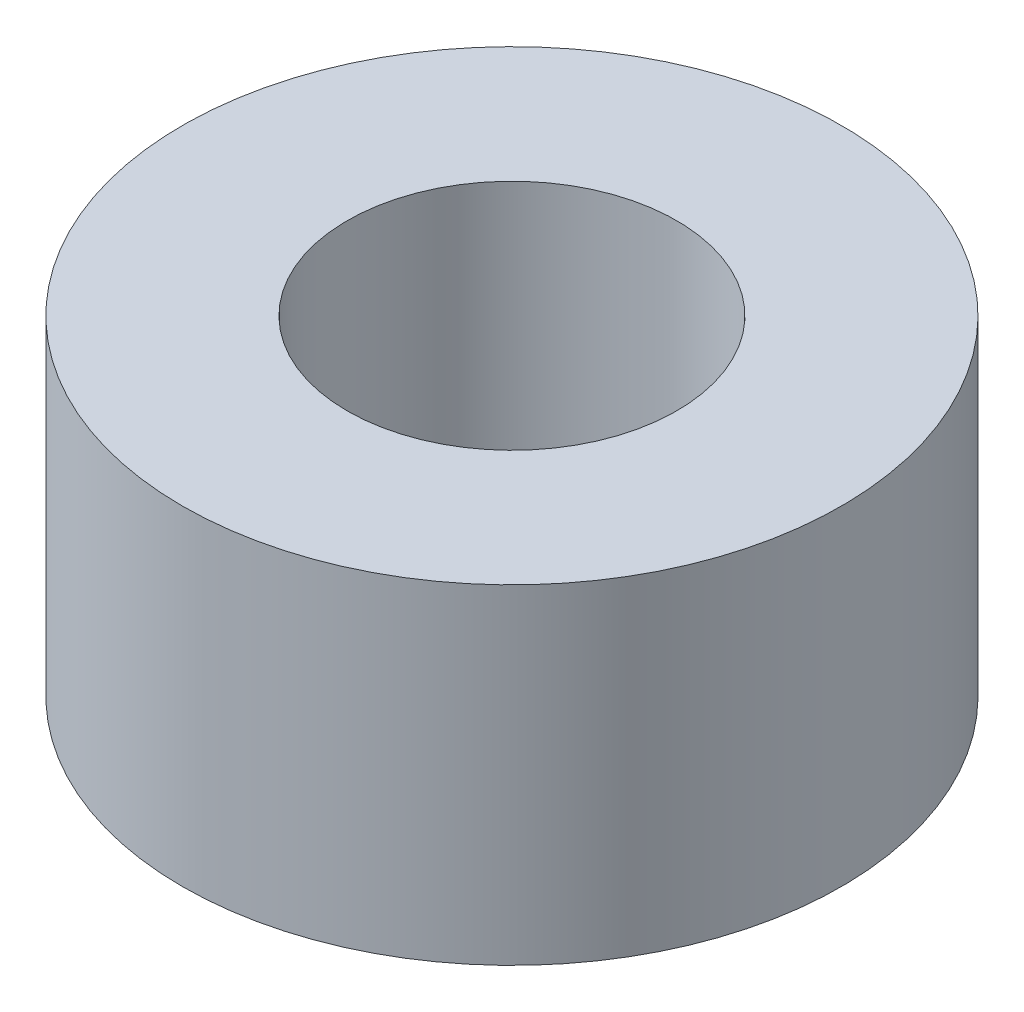
from build123d import *

# Parameters (mm, degrees)
SKETCH1_R           = 5.08
SKETCH1_R_2         = 2.54
BOSS_EXTRUDE1_DEPTH = 5.08


with BuildPart() as part:
    # Sketch1 → Boss-Extrude1 (new body)
    with BuildSketch(Plane(origin=(0, 0, 0), x_dir=(1, 0, 0), z_dir=(0, 1, 0))):
        Circle(SKETCH1_R)
        Circle(SKETCH1_R_2, mode=Mode.SUBTRACT)
    extrude(amount=BOSS_EXTRUDE1_DEPTH)


solid = part.part
